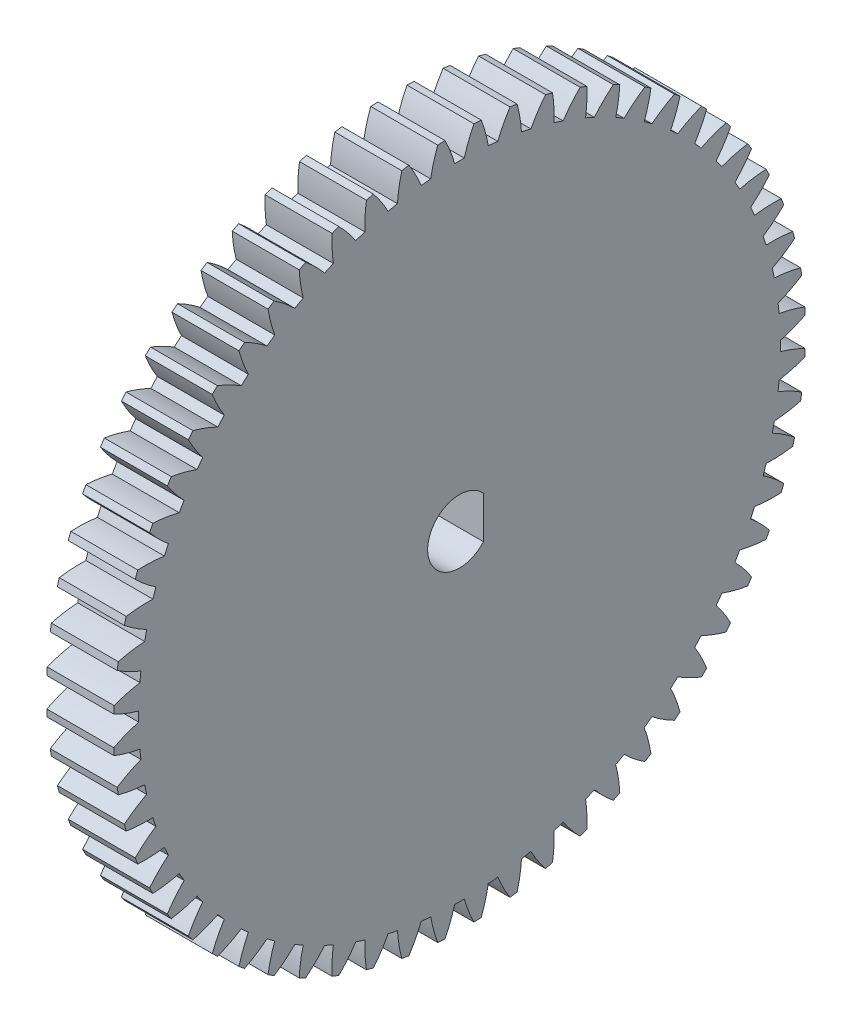
from build123d import *

# Parameters (mm, degrees)
BASPROSKE_W        = 6
BASPROSKE_H        = 31
TOOTHCUT_DEPTH     = 45.24929378
TEETHCUTS_COUNT    = 60
TEETHCUTS_ANGLE    = 354
CUT_EXTRUDE1_DEPTH = 45.211088099


with BuildPart() as part:
    # BasProSke → Base-Revolve (revolve)
    with BuildSketch(Plane(origin=(0, 0, 0), x_dir=(1, 0, 0), z_dir=(0, 1, 0)), mode=Mode.PRIVATE) as base_revolve_sk:
        with Locations((3, 15.5)):
            Rectangle(BASPROSKE_W, BASPROSKE_H)
    revolve(base_revolve_sk.sketch.rotate(Axis((-10, 0, 0), (1, 0, 0)), 180), axis=Axis((-10, 0, 0), (1, 0, 0)))

    # TooCutSke → ToothCut (cut, through all)
    with BuildSketch(Plane(origin=(0, 0, 0), x_dir=(0, 0, -1), z_dir=(1, 0, 0))):
        with BuildLine():
            ThreePointArc((0.430151971, 28.745781782), (0, 28.749), (-0.430151971, 28.745781782))
            ThreePointArc((-0.430151971, 28.745781782), (-0.81454129, 29.893990802), (-1.312684569, 30.997617721))
            ThreePointArc((-1.312684569, 30.997617721), (0, 31.0254), (1.312684569, 30.997617721))
            ThreePointArc((1.312684569, 30.997617721), (0.81454129, 29.893990802), (0.430151971, 28.745781782))
        make_face()
    toothcut = extrude(amount=TOOTHCUT_DEPTH, mode=Mode.SUBTRACT)

    # TeethCuts: ToothCut ×60 about axis
    teethcuts_axis = Axis((-10, 0, 0), (1, 0, 0))
    for i in range(1, TEETHCUTS_COUNT):
        add(toothcut.rotate(teethcuts_axis, i * TEETHCUTS_ANGLE / (TEETHCUTS_COUNT - 1)), mode=Mode.SUBTRACT)

    # Sketch1 → Cut-Extrude1 (cut, through all)
    with BuildSketch(Plane(origin=(6, 0, 0), x_dir=(0, 0, -1), z_dir=(1, 0, 0))):
        with BuildLine():
            Line((2.146363203, 1.875), (2.146363203, -1.875))
            ThreePointArc((2.146363203, -1.875), (-2.85, 0), (2.146363203, 1.875))
        make_face()
    extrude(amount=-CUT_EXTRUDE1_DEPTH, mode=Mode.SUBTRACT)


solid = part.part
